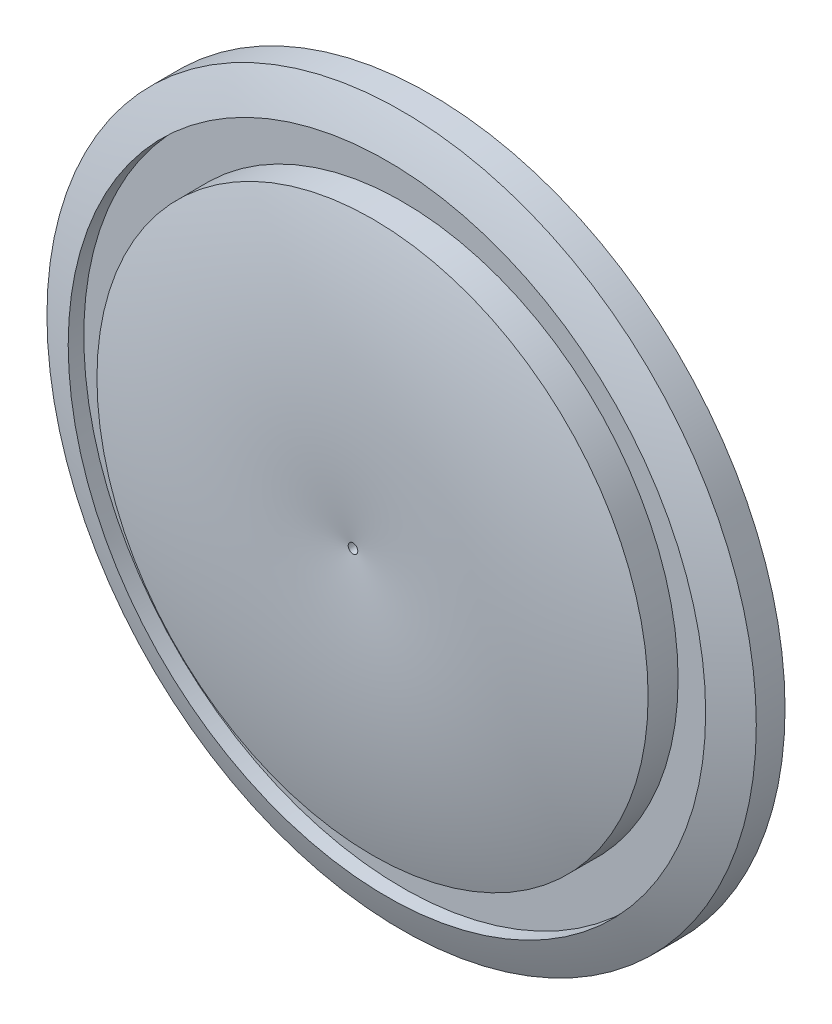
from build123d import *

# Parameters (mm, degrees)
SKETCH2_R          = 0.5
CUT_EXTRUDE1_DEPTH = 9.746515042
SKETCH3_R          = 33.25
SKETCH3_R_2        = 28.75
CUT_EXTRUDE3_DEPTH = 7.5


with BuildPart() as part:
    # Sketch1 → Revolve1 (revolve)
    with BuildSketch(Plane(origin=(0, 0, 0), x_dir=(1, 0, 0), z_dir=(0, 1, 0))):
        with BuildLine():
            Line((0, 2.406901823), (-37, 2.406901823))
            Line((-37, 2.406901823), (-37, -0.593098177))
            ThreePointArc((-37, -0.593098177), (-18.857679345, -5.739925328), (0, -5.593098177))
            Line((0, -5.593098177), (0, 2.406901823))
        make_face()
    revolve(axis=Axis((0, 0, -18.524642857), (0, 0, 1)))

    # Sketch2 → Cut-Extrude1 (cut, through all)
    with BuildSketch(Plane(origin=(0, 0, -2.406901823), x_dir=(-1, 0, 0), z_dir=(0, 0, -1))):
        Circle(SKETCH2_R)
    extrude(amount=-CUT_EXTRUDE1_DEPTH, mode=Mode.SUBTRACT)

    # Sketch3 → Cut-Extrude3 (cut)
    with BuildSketch(Plane.XY.offset(8)):
        Circle(SKETCH3_R)
        Circle(SKETCH3_R_2, mode=Mode.SUBTRACT)
    extrude(amount=-CUT_EXTRUDE3_DEPTH, mode=Mode.SUBTRACT)


solid = part.part
